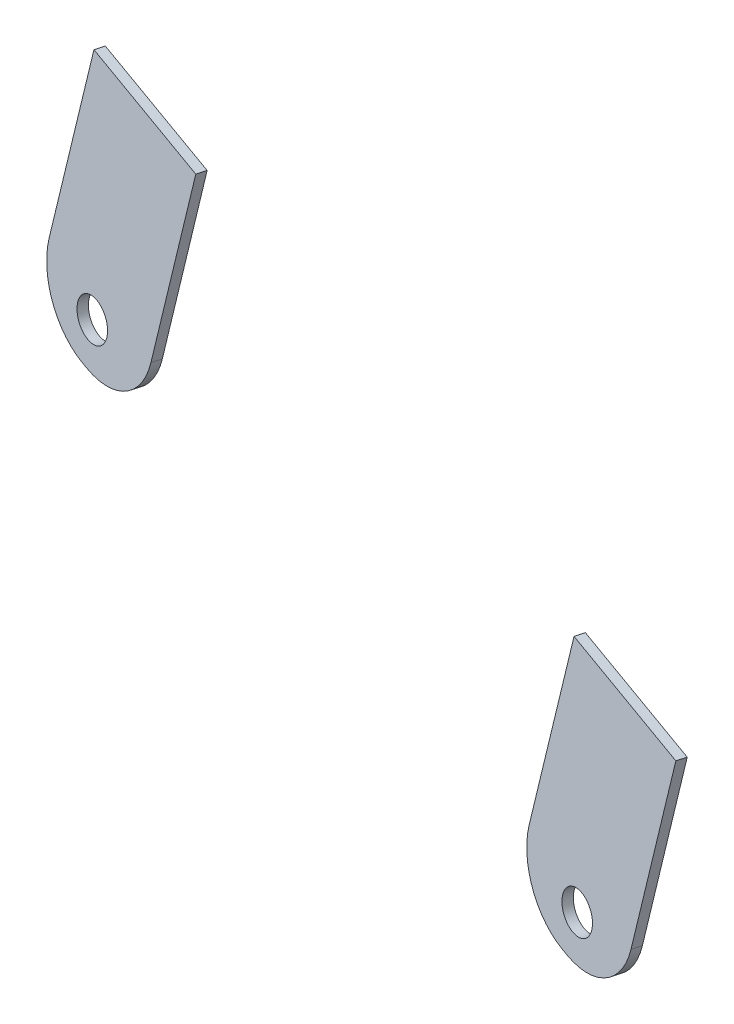
from build123d import *

# Parameters (mm, degrees)
SZKIC_3D4_R                   = 3
DODANIE_WYCI_GNI_CIE2_DEPTH   = 1.5
DODANIE_WYCI_GNI_CIE2_2_DEPTH = 1.5
DODANIE_WYCI_GNI_CIE3_DEPTH   = 13


with BuildPart() as part:
    # Szkic 3D4 → Dodanie-wyciągnięcie2 (new body)
    with BuildSketch(Plane(origin=(1025.706038393, -216.288954709, 105.318664983), x_dir=(0.9171838518362587, -0.34192929079965745, 0.20459262455926217), z_dir=(0.19549461704670756, -0.061265743629640455, -0.9787892333711423))):
        with BuildLine():
            Line((0, 0), (20.815785914, -2.775438122))
            Line((20.815785914, -2.775438122), (22.930405436, 13.084208289))
            ThreePointArc((22.930405436, 13.084208289), (20.961704759, 20.480346566), (14.33976363, 24.318124497))
            Line((14.33976363, 24.318124497), (13.348535729, 24.450288217))
            ThreePointArc((13.348535729, 24.450288217), (5.952397453, 22.48158754), (2.114619521, 15.859646411))
            Line((2.114619521, 15.859646411), (0, 0))
        make_face()
        with Locations(Location((12.480994513, 17.943729095, 0), (0, 0, 339.966298259))):
            Circle(SZKIC_3D4_R, mode=Mode.SUBTRACT)
    extrude(amount=-DODANIE_WYCI_GNI_CIE2_DEPTH)



with BuildPart() as body_2:
    # Szkic 3D4 → Dodanie-wyci_gni_cie2 2 (new body)
    with BuildSketch(Plane(origin=(1025.706038393, -216.288954709, 105.318664983), x_dir=(0.9171838518362587, -0.34192929079965745, 0.20459262455926217), z_dir=(0.19549461704670756, -0.061265743629640455, -0.9787892333711423))):
        with BuildLine():
            Line((98.131562168, -13.084208289), (118.947348082, -15.859646411))
            Line((118.947348082, -15.859646411), (121.061967603, 0))
            ThreePointArc((121.061967603, 0), (119.093266926, 7.396138277), (112.471325797, 11.233916208))
            Line((112.471325797, 11.233916208), (111.480097897, 11.366079928))
            ThreePointArc((111.480097897, 11.366079928), (104.08395962, 9.397379251), (100.246181689, 2.775438122))
            Line((100.246181689, 2.775438122), (98.131562168, -13.084208289))
        make_face()
        with Locations(Location((111.603784581, 4.727357086, 0), (0, 0, 339.966298259))):
            Circle(SZKIC_3D4_R, mode=Mode.SUBTRACT)
    extrude(amount=-DODANIE_WYCI_GNI_CIE2_2_DEPTH)


with BuildPart() as part_1:
    add(part.part)

    add(body_2.part)  # Dodanie-wyciągnięcie3 merges body 2
    # Szkic1 → Dodanie-wyciągnięcie3 (add)
    with BuildSketch(Plane(origin=(3.595584722, 15.719361841, -0.265778296), x_dir=(0.9748305613773303, -0.22291516630614797, 0.003768983345872848), z_dir=(0.22294702645417608, 0.9746912536391572, -0.016479789882437416))):
        Polygon((1145.188635005, -122.97038823), (1165.762021577, -127.181773388), (1166.062834802, -125.712245776), (1145.48944823, -121.500860618), align=None)
        Polygon((1048.199812593, -103.116715341), (1068.773199165, -107.3281005), (1069.074012391, -105.858572887), (1048.500625819, -101.647187729), align=None)
    extrude(amount=DODANIE_WYCI_GNI_CIE3_DEPTH)


solid = part_1.part
